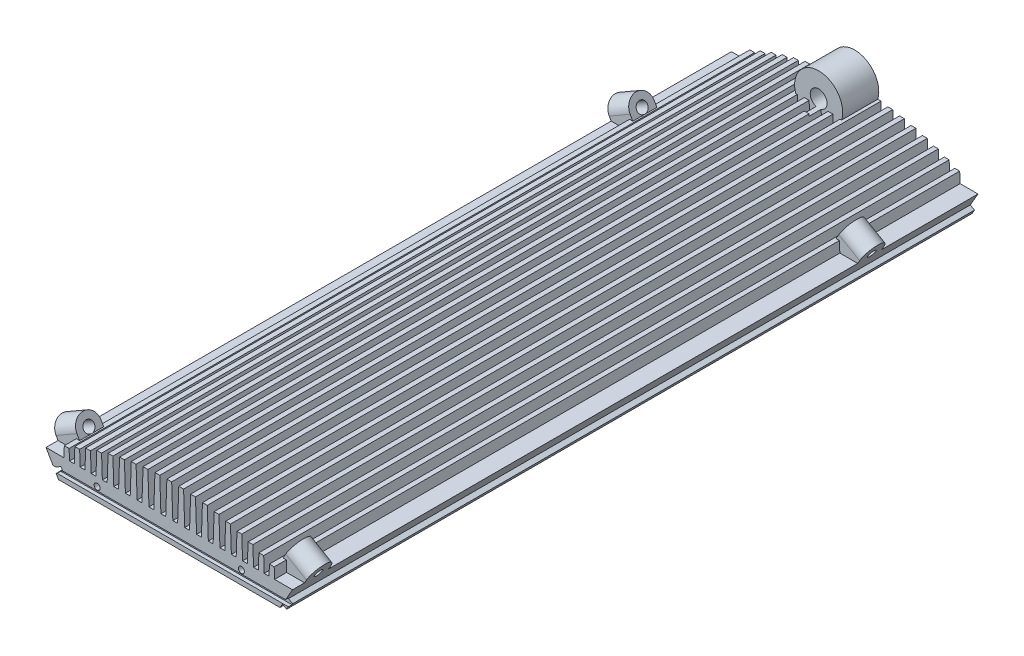
from build123d import *

# Parameters (mm, degrees)
RESSALTO_EXTRUS_O1_DEPTH   = 285
CORTE_EXTRUS_O1_DEPTH      = 286
RESSALTO_EXTRUS_O3_DEPTH   = 285
ESBO_O13_W                 = 1.5
ESBO_O13_H                 = 2
CORTE_EXTRUS_O7_DEPTH      = 52.25
CORTE_EXTRUS_O7_DEPTH_BACK = 52.25
ESBO_O5_R                  = 1.25
CORTE_EXTRUS_O3_DEPTH      = 10
ESBO_O6_W                  = 10
ESBO_O6_H                  = 6.20801671
RESSALTO_EXTRUS_O4_DEPTH   = 10
ESBO_O7_R                  = 2.25
CORTE_EXTRUS_O4_DEPTH      = 10
RESSALTO_EXTRUS_O5_DEPTH   = 10
ESBO_O9_R                  = 1.65
CORTE_EXTRUS_O5_DEPTH      = 10
PADR_O_LINEAR1_COUNT       = 2
PADR_O_LINEAR1_PITCH       = 230
RESSALTO_EXTRUS_O6_DEPTH   = 15
ESBO_O12_R                 = 3.5
CORTE_EXTRUS_O6_DEPTH      = 20
ESBO_O14_R                 = 1.65
ESBO_O14_R_2               = 1.25
CORTE_EXTRUS_O8_DEPTH      = 8


with BuildPart() as part:
    # Esboço1 → Ressalto-extrusão1 (new body)
    with BuildSketch(Plane.XY):
        Polygon((-46.053847577, 79.767603888), (-51.25, 88.767603888), (-43.793852831, 88.767603888), (-43.638704687, 93.210465413), (-41.638704687, 93.210465413), (-41.483556544, 88.767603888), (-39.483556544, 88.767603888), (-39.2627546, 95.090544274), (-37.2627546, 95.090544274), (-37.041952657, 88.767603888), (-35.041952657, 88.767603888), (-34.762153878, 96.779992589), (-32.762153878, 96.779992589), (-32.482355099, 88.767603888), (-30.482355099, 88.767603888), (-30.150613158, 98.267450117), (-28.150613158, 98.267450117), (-27.818871218, 88.767603888), (-25.818871218, 88.767603888), (-25.442585893, 99.543005756), (-23.442585893, 99.543005756), (-23.066300568, 88.767603888), (-21.066300568, 88.767603888), (-20.653166143, 100.598225931), (-18.653166143, 100.598225931), (-18.240031718, 88.767603888), (-16.240031718, 88.767603888), (-15.797984557, 101.426178342), (-13.797984557, 101.426178342), (-13.355937397, 88.767603888), (-11.355937397, 88.767603888), (-10.893102848, 102.021451254), (-8.893102848, 102.021451254), (-8.430268299, 88.767603888), (-6.430268299, 88.767603888), (-5.954907069, 102.38016847), (-3.954907069, 102.38016847), (-3.479545839, 88.767603888), (-1.479545839, 88.767603888), (-1, 102.5), (1, 102.5), (1.479545839, 88.767603888), (3.479545839, 88.767603888), (3.954907069, 102.38016847), (5.954907069, 102.38016847), (6.430268299, 88.767603888), (8.430268299, 88.767603888), (8.893102848, 102.021451254), (10.893102848, 102.021451254), (11.355937397, 88.767603888), (13.355937397, 88.767603888), (13.797984557, 101.426178342), (15.797984557, 101.426178342), (16.240031718, 88.767603888), (18.240031718, 88.767603888), (18.653166143, 100.598225931), (20.653166143, 100.598225931), (21.066300568, 88.767603888), (23.066300568, 88.767603888), (23.442585893, 99.543005756), (25.442585893, 99.543005756), (25.818871218, 88.767603888), (27.818871218, 88.767603888), (28.150613158, 98.267450117), (30.150613158, 98.267450117), (30.482355099, 88.767603888), (32.482355099, 88.767603888), (32.762153878, 96.779992589), (34.762153878, 96.779992589), (35.041952657, 88.767603888), (37.041952657, 88.767603888), (37.2627546, 95.090544274), (39.2627546, 95.090544274), (39.483556544, 88.767603888), (41.483556544, 88.767603888), (41.638704687, 93.210465413), (43.638704687, 93.210465413), (43.793852831, 88.767603888), (51.25, 88.767603888), (46.053847577, 79.767603888), align=None)
    extrude(amount=RESSALTO_EXTRUS_O1_DEPTH)

    # Esboço2 → Corte-extrusão1 (cut, through all)
    with BuildSketch(Plane.XY.offset(285)):
        Polygon((-47.053847577, 81.499654695), (-44.022758664, 83.249654695), (-45.022758664, 84.981705503), (-48.053847577, 83.231705503), align=None)
    extrude(amount=-CORTE_EXTRUS_O1_DEPTH, mode=Mode.SUBTRACT)


with BuildPart() as body_2:
    # Esboço3 → Ressalto-extrusão3 (new body)
    with BuildSketch(Plane.XY.offset(285)):
        Polygon((47.053847577, 81.499654695), (48.053847577, 83.231705503), (49.785898385, 82.231705503), (48.785898385, 80.499654695), align=None)
    extrude(amount=-RESSALTO_EXTRUS_O3_DEPTH)


with BuildPart() as corte_extrus_o7_tool:
    # Esboço13 → Corte-extrusão7 (new body, two sides)
    with BuildSketch(Plane(origin=(0, 0, 0), x_dir=(0, 0, -1), z_dir=(1, 0, 0))) as corte_extrus_o7_sk:
        with Locations((-284.25, 82.767603888)):
            Rectangle(ESBO_O13_W, ESBO_O13_H)
    extrude(amount=CORTE_EXTRUS_O7_DEPTH)
    extrude(corte_extrus_o7_sk.sketch, amount=-CORTE_EXTRUS_O7_DEPTH_BACK)


with BuildPart() as part_1:
    add(part.part)

    # Corte-extrusão7: cut by corte_extrus_o7_tool
    add(corte_extrus_o7_tool.part, mode=Mode.SUBTRACT)

    # Esboço5 → Corte-extrusão3 (cut)
    with BuildSketch(Plane.XY.offset(285)):
        with Locations((-30, 85.267603888)):
            Circle(ESBO_O5_R)
        with Locations((30, 85.267603888)):
            Circle(ESBO_O5_R)
    extrude(amount=-CORTE_EXTRUS_O3_DEPTH, mode=Mode.SUBTRACT)

    # Esboço6 → Ressalto-extrusão4 (add)
    with BuildSketch(Plane(origin=(0, 0, 0), x_dir=(0, 0, 1), z_dir=(-0.866025404, -0.5, 0))):
        with BuildLine():
            Line((280, 102.5), (280, 104.107695155))
            ThreePointArc((280, 104.107695155), (275, 109.107695155), (270, 104.107695155))
            Line((270, 104.107695155), (270, 102.5))
            Line((270, 102.5), (280, 102.5))
        make_face()
        with Locations((275, 99.395991645)):
            Rectangle(ESBO_O6_W, ESBO_O6_H)
    ressalto_extrus_o4 = extrude(amount=-RESSALTO_EXTRUS_O4_DEPTH)

    # Esboço7 → Corte-extrusão4 (cut)
    with BuildSketch(Plane(origin=(0, 0, 0), x_dir=(0, 0, 1), z_dir=(-0.866025404, -0.5, 0))):
        with Locations((275, 104.107695155)):
            Circle(ESBO_O7_R)
    corte_extrus_o4 = extrude(amount=-CORTE_EXTRUS_O4_DEPTH, mode=Mode.SUBTRACT)



with BuildPart() as body_2_1:
    add(body_2.part)

    # Corte-extrusão7: cut by corte_extrus_o7_tool
    add(corte_extrus_o7_tool.part, mode=Mode.SUBTRACT)


with BuildPart() as part_2:
    add(part_1.part)

    add(body_2_1.part)  # Ressalto-extrusão5 merges body 2
    # Esboço8 → Ressalto-extrusão5 (add)
    with BuildSketch(Plane(origin=(0, 0, 0), x_dir=(0, 0, -1), z_dir=(0.866025404, -0.5, 0))):
        with BuildLine():
            Line((-280, 104.107695155), (-280, 96.107695155))
            Line((-280, 96.107695155), (-270, 96.107695155))
            Line((-270, 96.107695155), (-270, 104.107695155))
            ThreePointArc((-270, 104.107695155), (-275, 109.107695155), (-280, 104.107695155))
        make_face()
    ressalto_extrus_o5 = extrude(amount=-RESSALTO_EXTRUS_O5_DEPTH)

    # Esboço9 → Corte-extrusão5 (cut)
    with BuildSketch(Plane(origin=(0, 0, 0), x_dir=(0, 0, -1), z_dir=(0.866025404, -0.5, 0))):
        with Locations((-275, 104.107695155)):
            Circle(ESBO_O9_R)
    corte_extrus_o5 = extrude(amount=-CORTE_EXTRUS_O5_DEPTH, mode=Mode.SUBTRACT)

    # Padrão linear1: Ressalto-extrusão4, Corte-extrusão4, Ressalto-extrusão5, Corte-extrusão5 ×2
    with Locations(*[(0, 0, -i * PADR_O_LINEAR1_PITCH) for i in range(1, PADR_O_LINEAR1_COUNT)]):
        add(ressalto_extrus_o4)
        add(corte_extrus_o4, mode=Mode.SUBTRACT)
        add(ressalto_extrus_o5)
        add(corte_extrus_o5, mode=Mode.SUBTRACT)

    # Esboço10 → Ressalto-extrusão6 (add)
    with BuildSketch(Plane(origin=(0, 0, 0), x_dir=(-1, 0, 0), z_dir=(0, 0, -1))):
        with BuildLine():
            Line((10.893102848, 102.021451254), (9.546111648, 102.021451254))
            ThreePointArc((9.546111648, 102.021451254), (0, 114.999999962), (-9.546111648, 102.021451254))
            Line((-9.546111648, 102.021451254), (-10.893102848, 102.021451254))
            Line((-10.893102848, 102.021451254), (-10.893102848, 84.600519771))
            Line((-10.893102848, 84.600519771), (10.893102848, 84.600519771))
            Line((10.893102848, 84.600519771), (10.893102848, 102.021451254))
        make_face()
    extrude(amount=-RESSALTO_EXTRUS_O6_DEPTH)

    # Esboço12 → Corte-extrusão6 (cut)
    with BuildSketch(Plane(origin=(0, 0, 0), x_dir=(-1, 0, 0), z_dir=(0, 0, -1))):
        with Locations((0, 104.999999962)):
            Circle(ESBO_O12_R)
    extrude(amount=-CORTE_EXTRUS_O6_DEPTH, mode=Mode.SUBTRACT)

    # Esboço14 → Corte-extrusão8 (cut)
    with BuildSketch(Plane(origin=(0, 79.767603888, 0), x_dir=(-1, 0, 0), z_dir=(0, -1, 0))):
        with Locations((-36.5, -246.65)):
            Circle(ESBO_O14_R)
        with Locations((-21.254, -234.65)):
            Circle(ESBO_O14_R_2)
        with Locations((36.5, -246.65)):
            Circle(ESBO_O14_R)
        with Locations((22.307, -180.42)):
            Circle(ESBO_O14_R_2)
        with Locations((38.5, -26.15)):
            Circle(ESBO_O14_R)
        with Locations((15.449, -26.242)):
            Circle(ESBO_O14_R_2)
        with Locations((15.83, -8.335)):
            Circle(ESBO_O14_R_2)
        with Locations((-32.5, -12.65)):
            Circle(ESBO_O14_R)
        with Locations((-25.572, -49.15)):
            Circle(ESBO_O14_R_2)
        with Locations((-21.762, -76.661)):
            Circle(ESBO_O14_R_2)
        with Locations((25.863, -97.743)):
            Circle(ESBO_O14_R_2)
        with Locations((-27.096, -173.943)):
            Circle(ESBO_O14_R_2)
        with Locations((-38.145, -142.066)):
            Circle(ESBO_O14_R)
        with Locations((-17.500001526, -217.649999573)):
            Circle(ESBO_O14_R_2)
        with Locations((-17.500001526, -197.649999573)):
            Circle(ESBO_O14_R_2)
        with Locations((-17.5, -177.65)):
            Circle(ESBO_O14_R_2)
        with Locations((-17.500001526, -157.649999573)):
            Circle(ESBO_O14_R_2)
        with Locations((17.499998474, -127.649991943)):
            Circle(ESBO_O14_R_2)
        with Locations((17.499998474, -107.650007202)):
            Circle(ESBO_O14_R_2)
        with Locations((17.499998474, -87.650007202)):
            Circle(ESBO_O14_R_2)
        with Locations((17.499998474, -67.649991943)):
            Circle(ESBO_O14_R_2)
    extrude(amount=-CORTE_EXTRUS_O8_DEPTH, mode=Mode.SUBTRACT)


solid = part_2.part
